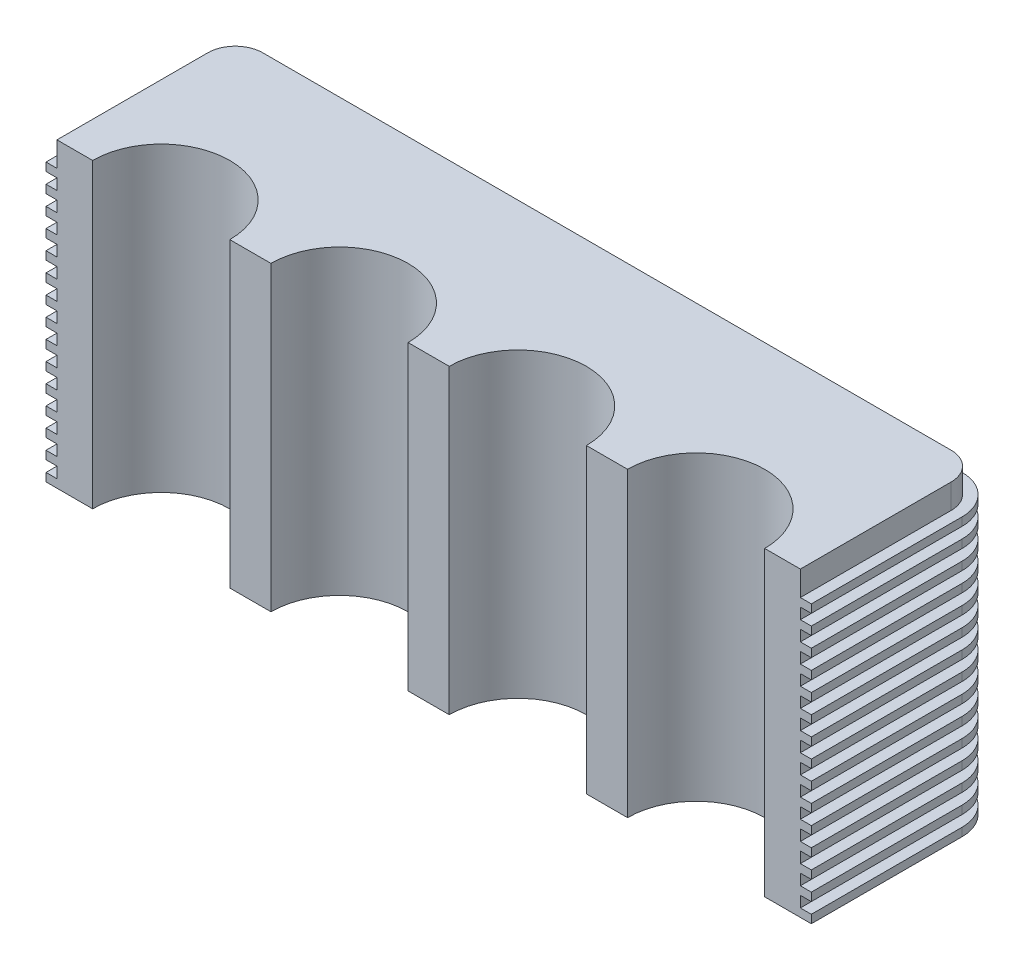
from build123d import *

# Parameters (mm, degrees)
BOSS_EXTRUDE1_DEPTH = 110
BOSS_EXTRUDE2_DEPTH = 3
LPATTERN1_COUNT     = 15
LPATTERN1_PITCH     = 7


with BuildPart() as part:
    # Sketch1 → Boss-Extrude1 (new body)
    with BuildSketch(Plane(origin=(0, 0, 0), x_dir=(1, 0, 0), z_dir=(0, 1, 0))):
        with BuildLine():
            Line((0, 0), (13, 0))
            ThreePointArc((13, 0), (38, 25), (63, 0))
            Line((63, 0), (78, 0))
            ThreePointArc((78, 0), (103, 25), (128, 0))
            Line((128, 0), (143, 0))
            ThreePointArc((143, 0), (168, 25), (193, 0))
            Line((193, 0), (208, 0))
            ThreePointArc((208, 0), (233, 25), (258, 0))
            Line((258, 0), (271, 0))
            Line((271, 0), (271, 55))
            ThreePointArc((271, 55), (268.071067812, 62.071067812), (261, 65))
            Line((261, 65), (10, 65))
            ThreePointArc((10, 65), (2.928932188, 62.071067812), (0, 55))
            Line((0, 55), (0, 0))
        make_face()
    extrude(amount=BOSS_EXTRUDE1_DEPTH)

    # Sketch2 → Boss-Extrude2 (add)
    with BuildSketch(Plane(origin=(0, 0, 0), x_dir=(1, 0, 0), z_dir=(0, 1, 0))):
        with BuildLine():
            Line((275, 0), (275, 55))
            ThreePointArc((275, 55), (270.899494937, 64.899494937), (261, 69))
            Line((261, 69), (10, 69))
            ThreePointArc((10, 69), (0.100505063, 64.899494937), (-4, 55))
            Line((-4, 55), (-4, 0))
            Line((-4, 0), (0, 0))
            Line((0, 0), (0, 55))
            ThreePointArc((0, 55), (2.928932188, 62.071067812), (10, 65))
            Line((10, 65), (261, 65))
            ThreePointArc((261, 65), (268.071067812, 62.071067812), (271, 55))
            Line((271, 55), (271, 0))
            Line((271, 0), (275, 0))
        make_face()
    boss_extrude2 = extrude(amount=BOSS_EXTRUDE2_DEPTH)

    # LPattern1: Boss-Extrude2 ×15
    with Locations(*[(0, i * LPATTERN1_PITCH, 0) for i in range(1, LPATTERN1_COUNT)]):
        add(boss_extrude2)


solid = part.part
